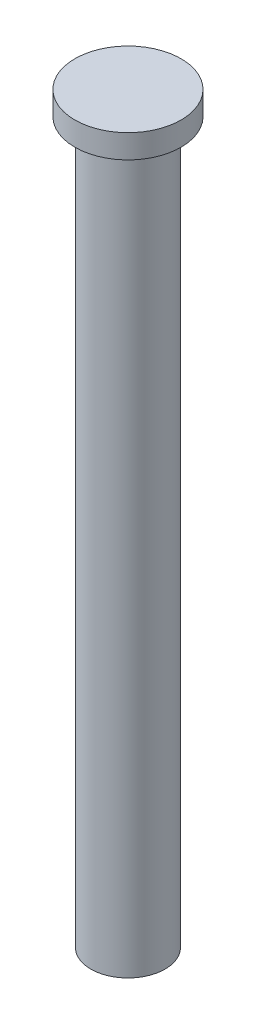
from build123d import *

# Parameters (mm, degrees)
ESQUISSE1_R        = 3.15
BOSS_EXTRU_1_DEPTH = 61
ESQUISSE3_R        = 4.5
BOSS_EXTRU_2_DEPTH = 2


with BuildPart() as part:
    # Esquisse1 → Boss.-Extru.1 (new body)
    with BuildSketch(Plane(origin=(0, 0, 0), x_dir=(1, 0, 0), z_dir=(0, 1, 0))):
        Circle(ESQUISSE1_R)
    extrude(amount=BOSS_EXTRU_1_DEPTH)

    # Esquisse3 → Boss.-Extru.2 (add)
    with BuildSketch(Plane(origin=(0, 61, 0), x_dir=(1, 0, 0), z_dir=(0, 1, 0))):
        Circle(ESQUISSE3_R)
    extrude(amount=BOSS_EXTRU_2_DEPTH)


solid = part.part
